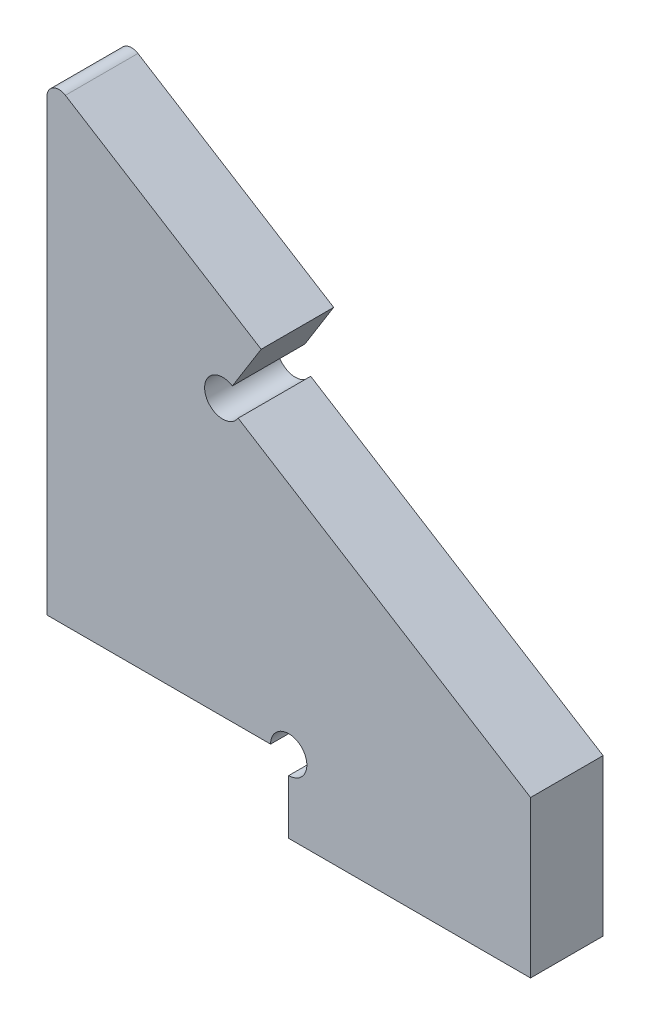
from build123d import *

# Parameters (mm, degrees)
BOSS_EXTRUDE1_START     = -3
SKETCH1_W               = 20
SKETCH1_H               = 6
BOSS_EXTRUDE1_DEPTH     = 6
BOSS_EXTRUDE2_REACH     = 713.032
SKETCH2_W               = 40
SKETCH2_H               = 6
SKETCH3_R               = 1.5
CUT_EXTRUDE1_DEPTH      = 730.905928511
FILLET1_R               = 1
CUT_EXTRUDE3_DEPTH      = 730.725112263
CUT_EXTRUDE3_DEPTH_BACK = 730.725112263
SKETCH5_R               = 1.5
CUT_EXTRUDE4_DEPTH      = 730.725112263


with BuildPart() as part:
    # Sketch1 → Boss-Extrude1 (new body)
    with BuildSketch(Plane.XY.offset(BOSS_EXTRUDE1_START)):
        with Locations((701, 123)):
            Rectangle(SKETCH1_W, SKETCH1_H)
    extrude(amount=BOSS_EXTRUDE1_DEPTH)

    # Boss-Extrude2: up to this plane
    boss_extrude2_end = Plane(origin=(261.902222158, 420.028150272, 347.5), z_dir=(-0.5291046610932348, -0.8485565730164449, 0))
    # Sketch2 → Boss-Extrude2 (add, up to the surface)
    with BuildSketch(Plane(origin=(0, 126, 0), x_dir=(1, 0, 0), z_dir=(0, 1, 0)), mode=Mode.PRIVATE) as boss_extrude2_sk1:
        with Locations((691, 0)):
            Rectangle(SKETCH2_W, SKETCH2_H)
    boss_extrude2_tool1 = split(extrude(boss_extrude2_sk1.sketch, amount=BOSS_EXTRUDE2_REACH, mode=Mode.PRIVATE), bisect_by=boss_extrude2_end, keep=Keep.BOTH, mode=Mode.PRIVATE)
    add(boss_extrude2_tool1.solids().sort_by_distance((691, 126, 0))[0])

    # Sketch3 → Cut-Extrude1 (cut, through all)
    with BuildSketch(Plane.XY.offset(3)):
        with Locations((691, 126)):
            Circle(SKETCH3_R)
    extrude(amount=-CUT_EXTRUDE1_DEPTH, mode=Mode.SUBTRACT)

    # Fillet1
    fillet1_edges = [part.edges().sort_by_distance(p)[0] for p in [
        (671, 164.941397093, 0),
    ]]
    fillet(fillet1_edges, radius=FILLET1_R)

    # Sketch4 → Cut-Extrude3 (cut, two sides)
    with BuildSketch(Plane.XY.offset(3)) as cut_extrude3_sk:
        Polygon((688.717930776, 153.893648414), (685.54330281, 148.802308976), (711, 132.929169143), (714.174627967, 138.020508582), align=None)
    extrude(amount=CUT_EXTRUDE3_DEPTH, mode=Mode.SUBTRACT)
    extrude(cut_extrude3_sk.sketch, amount=-CUT_EXTRUDE3_DEPTH_BACK, mode=Mode.SUBTRACT)

    # Sketch5 → Cut-Extrude4 (cut, through all)
    with BuildSketch(Plane.XY.offset(3)):
        with Locations((685.54330281, 148.802308976)):
            Circle(SKETCH5_R)
    extrude(amount=-CUT_EXTRUDE4_DEPTH, mode=Mode.SUBTRACT)


solid = part.part
